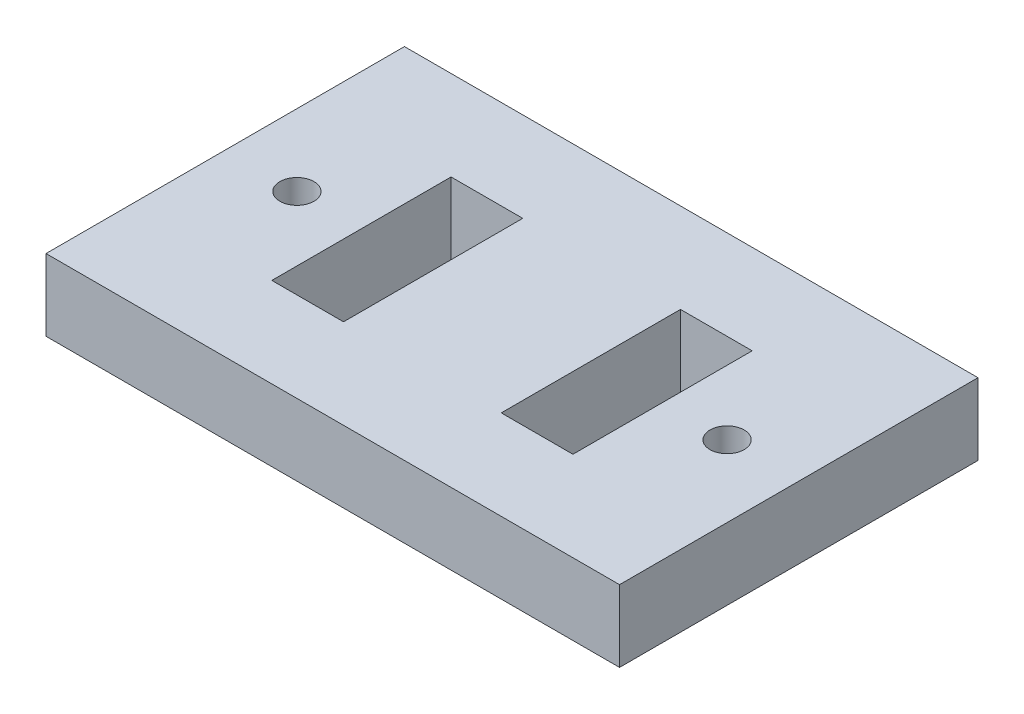
from build123d import *

# Parameters (mm, degrees)
SKETCH1_W           = 80
SKETCH1_H           = 50
BOSS_EXTRUDE1_DEPTH = 10
SKETCH2_R           = 2.38125
CUT_EXTRUDE1_DEPTH  = 10
SKETCH3_W           = 10
SKETCH3_H           = 25
CUT_EXTRUDE2_DEPTH  = 10


with BuildPart() as part:
    # Sketch1 → Boss-Extrude1 (new body)
    with BuildSketch(Plane(origin=(0, 0, 0), x_dir=(1, 0, 0), z_dir=(0, 1, 0))):
        Rectangle(SKETCH1_W, SKETCH1_H)
    extrude(amount=BOSS_EXTRUDE1_DEPTH)

    # Sketch2 → Cut-Extrude1 (cut)
    with BuildSketch(Plane(origin=(0, 10, 0), x_dir=(1, 0, 0), z_dir=(0, 1, 0))):
        with Locations((-30, 0)):
            Circle(SKETCH2_R)
        with Locations((30, 0)):
            Circle(SKETCH2_R)
    extrude(amount=-CUT_EXTRUDE1_DEPTH, mode=Mode.SUBTRACT)

    # Sketch3 → Cut-Extrude2 (cut)
    with BuildSketch(Plane(origin=(0, 10, 0), x_dir=(1, 0, 0), z_dir=(0, 1, 0))):
        with Locations((-16, 0)):
            Rectangle(SKETCH3_W, SKETCH3_H)
        with Locations((16, 0)):
            Rectangle(SKETCH3_W, SKETCH3_H)
    extrude(amount=-CUT_EXTRUDE2_DEPTH, mode=Mode.SUBTRACT)


solid = part.part
